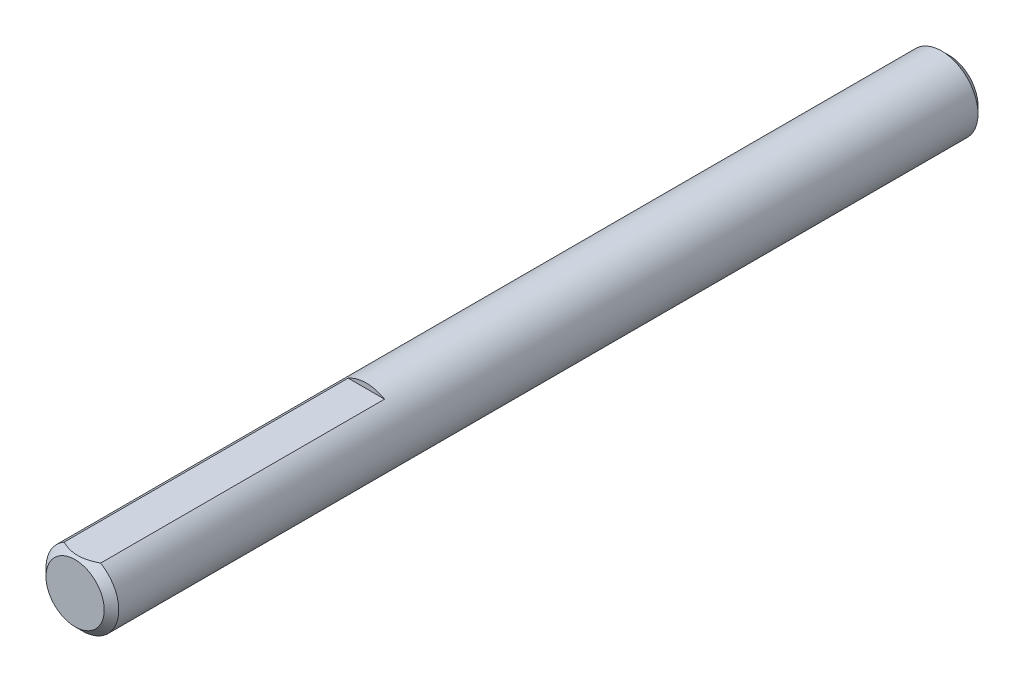
from build123d import *

# Parameters (mm, degrees)
SKETCH1_R      = 3.175
EXTRUDE1_DEPTH = 38.1
CHAMFER1_SIZE  = 0.635
EXTRUDE7_DEPTH = 26.4


with BuildPart() as part:
    # Sketch1 → Extrude1 (new body, symmetric)
    with BuildSketch(Plane.XY):
        Circle(SKETCH1_R)
    extrude(amount=EXTRUDE1_DEPTH, both=True)

    # Chamfer1
    chamfer1_edges = [part.edges().sort_by_distance(p)[0] for p in [
        (-3.175, 0, -38.1),
        (-3.175, 0, 38.1),
    ]]
    chamfer(chamfer1_edges, length=CHAMFER1_SIZE)

    # Sketch13 → Extrude7 (cut, through all)
    with BuildSketch(Plane.XY.offset(12.7)):
        with BuildLine():
            Line((-1.5875, 2.749630657), (1.5875, 2.749630657))
            ThreePointArc((1.5875, 2.749630657), (0, 3.175), (-1.5875, 2.749630657))
        make_face()
    extrude(amount=EXTRUDE7_DEPTH, mode=Mode.SUBTRACT)


solid = part.part
